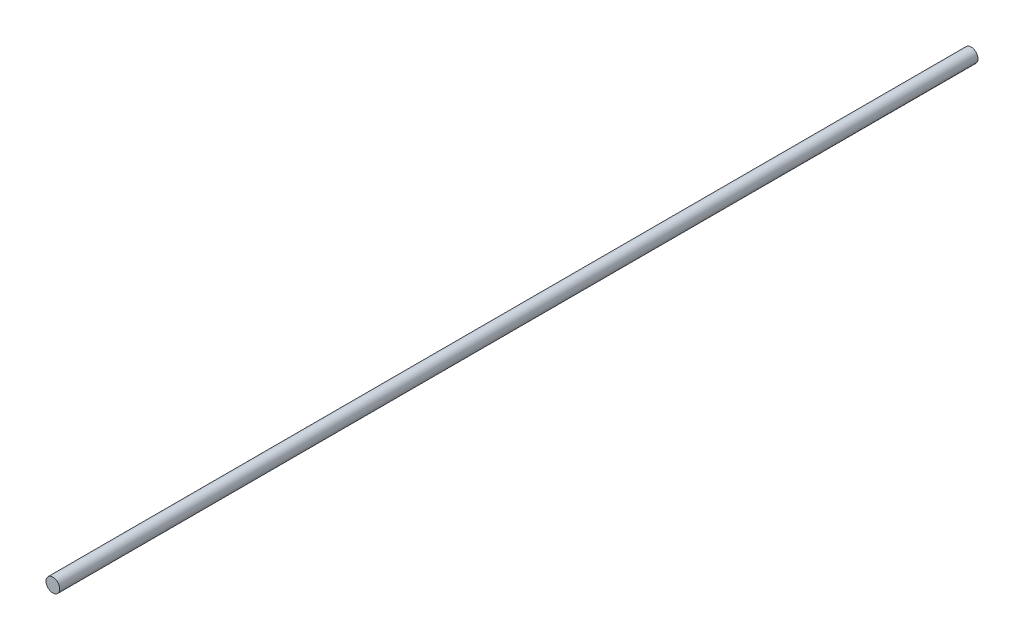
from build123d import *

# Parameters (mm, degrees)
SKETCH1_R           = 1.5
BOSS_EXTRUDE1_DEPTH = 200


with BuildPart() as part:
    # Sketch1 → Boss-Extrude1 (new body)
    with BuildSketch(Plane.XY):
        Circle(SKETCH1_R)
    extrude(amount=-BOSS_EXTRUDE1_DEPTH)


solid = part.part
